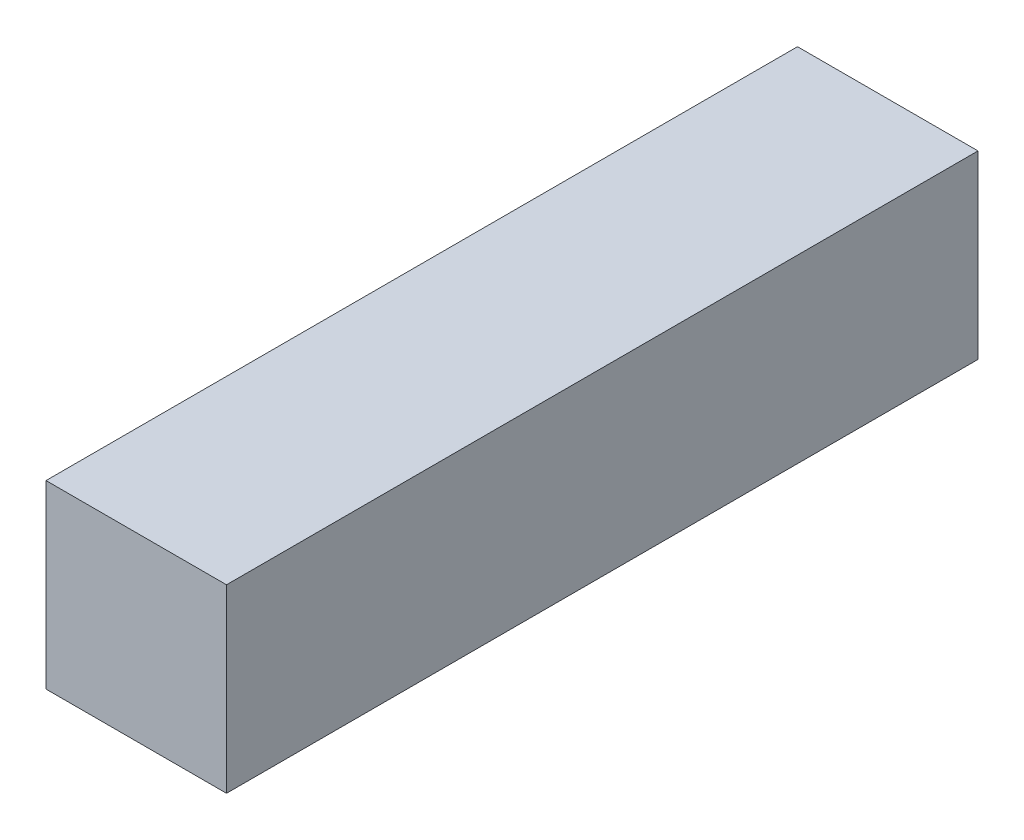
from build123d import *

# Parameters (mm, degrees)
SKETCH1_W           = 4.7625
SKETCH1_H           = 4.76504
BOSS_EXTRUDE1_DEPTH = 19.8272


with BuildPart() as part:
    # Sketch1 → Boss-Extrude1 (new body)
    with BuildSketch(Plane.XY):
        with Locations((2.38125, 2.38252)):
            Rectangle(SKETCH1_W, SKETCH1_H)
    extrude(amount=BOSS_EXTRUDE1_DEPTH)


solid = part.part
